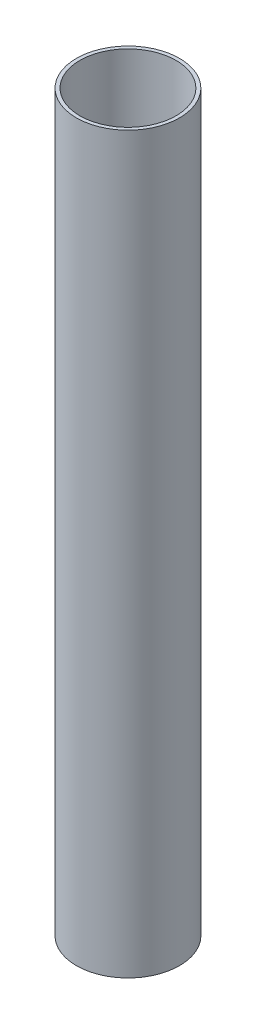
from build123d import *

# Parameters (mm, degrees)
SKETCH1_R           = 29.5
SKETCH1_R_2         = 27.5
BOSS_EXTRUDE1_DEPTH = 420


with BuildPart() as part:
    # Sketch1 → Boss-Extrude1 (new body)
    with BuildSketch(Plane(origin=(0, 0, 0), x_dir=(1, 0, 0), z_dir=(0, 1, 0))):
        Circle(SKETCH1_R)
        Circle(SKETCH1_R_2, mode=Mode.SUBTRACT)
    extrude(amount=BOSS_EXTRUDE1_DEPTH)


solid = part.part
